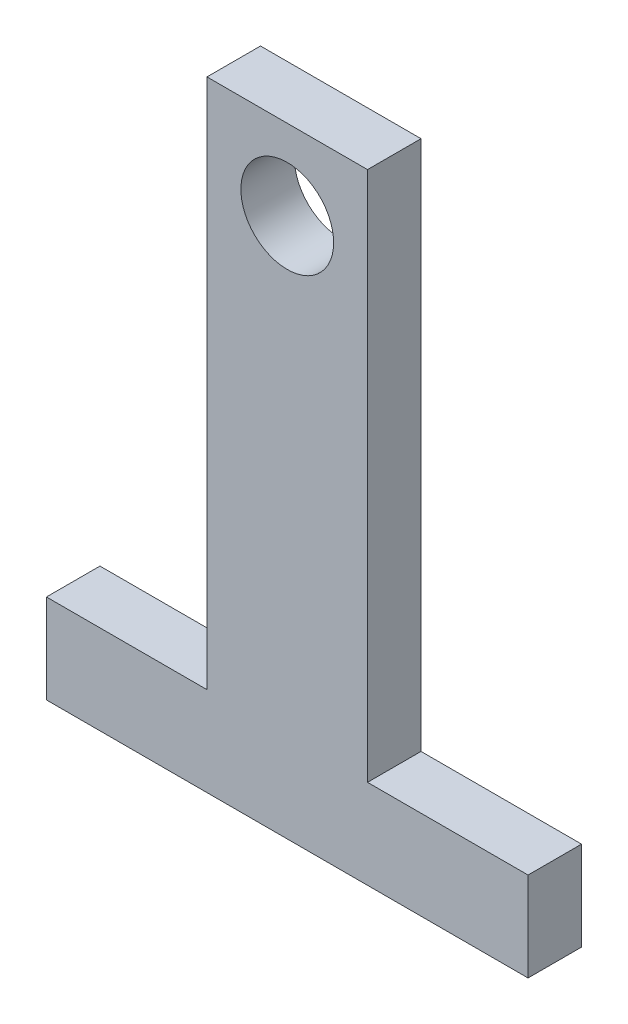
from build123d import *

# Parameters (mm, degrees)
ESQUISSE1_R        = 2.6
BOSS_EXTRU_1_DEPTH = 3


with BuildPart() as part:
    # Esquisse1 → Boss.-Extru.1 (new body)
    with BuildSketch(Plane.XY):
        Polygon((-9, 0), (-18, 0), (-18, -5), (9, -5), (9, 0), (0, 0), (0, 29.75), (-9, 29.75), align=None)
        with Locations((-4.5, 25.25)):
            Circle(ESQUISSE1_R, mode=Mode.SUBTRACT)
    extrude(amount=BOSS_EXTRU_1_DEPTH)


solid = part.part
